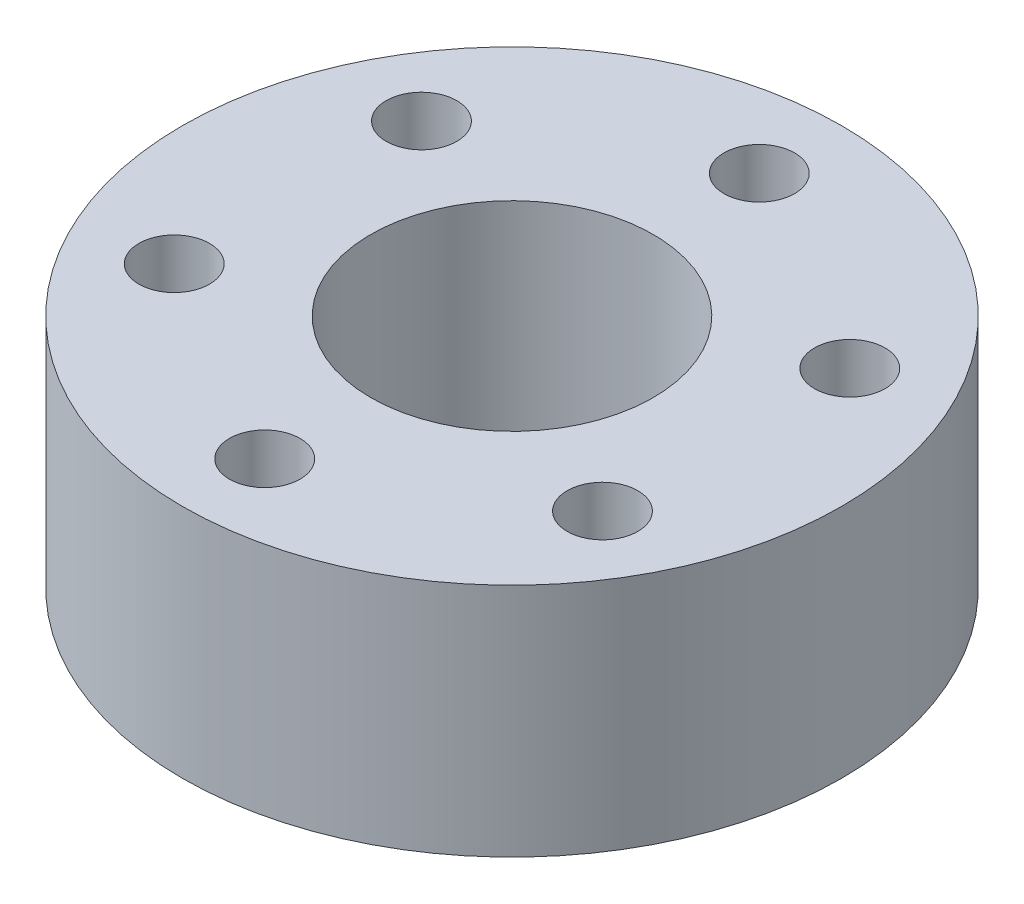
from build123d import *

# Parameters (mm, degrees)
SKETCH1_R           = 14
BOSS_EXTRUDE1_DEPTH = 10
SKETCH2_R           = 1.5
SKETCH2_R_2         = 6
CUT_EXTRUDE1_DEPTH  = 11


with BuildPart() as part:
    # Sketch1 → Boss-Extrude1 (new body)
    with BuildSketch(Plane(origin=(0, 0, 0), x_dir=(1, 0, 0), z_dir=(0, 1, 0))):
        Circle(SKETCH1_R)
    extrude(amount=BOSS_EXTRUDE1_DEPTH)

    # Sketch2 → Cut-Extrude1 (cut, through all)
    with BuildSketch(Plane(origin=(0, 10, 0), x_dir=(1, 0, 0), z_dir=(0, 1, 0))):
        with Locations((0, 10.5)):
            Circle(SKETCH2_R)
        Circle(SKETCH2_R_2)
        with Locations((9.09326674, 5.25)):
            Circle(SKETCH2_R)
        with Locations((9.09326674, -5.25)):
            Circle(SKETCH2_R)
        with Locations((0, -10.5)):
            Circle(SKETCH2_R)
        with Locations((-9.09326674, -5.25)):
            Circle(SKETCH2_R)
        with Locations((-9.09326674, 5.25)):
            Circle(SKETCH2_R)
    extrude(amount=-CUT_EXTRUDE1_DEPTH, mode=Mode.SUBTRACT)


solid = part.part
